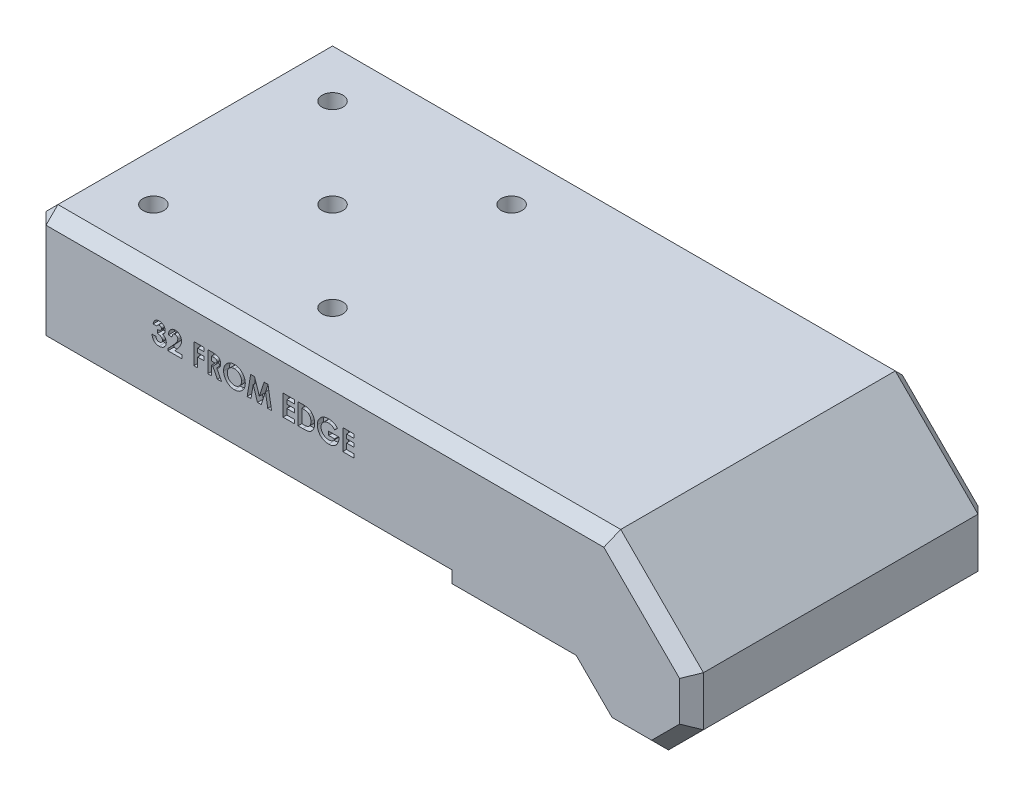
from build123d import *
from OCP.BRepFilletAPI import BRepFilletAPI_MakeChamfer

# Parameters (mm, degrees)
BOSS_EXTRUDE1_DEPTH = 50
SKETCH2_R           = 1.75
CUT_EXTRUDE1_DEPTH  = 107.695829347
CHAMFER1_SIZE       = 2
CHAMFER1_SIZE2      = 0.352653961
CUT_EXTRUDE2_DEPTH  = 1
CHAMFER2_SIZE       = 2


with BuildPart() as part:
    # Sketch1 → Boss-Extrude1 (new body)
    with BuildSketch(Plane.XY):
        Polygon((6, -6), (14.284271247, -6), (20.142135624, -0.142135624), (20.142135624, 8.142135624), (6.284271247, 22), (-90, 22), (-90, 2), (-22, 2), (-22, 0), (0, 0), align=None)
    extrude(amount=BOSS_EXTRUDE1_DEPTH)

    # Sketch2 → Cut-Extrude1 (cut, through all)
    with BuildSketch(Plane(origin=(0, 22, 0), x_dir=(1, 0, 0), z_dir=(0, 1, 0))):
        with Locations(Location((-80, -10, 0), (0, 0, 180))):
            Circle(SKETCH2_R)
        with Locations(Location((-50, -10, 0), (0, 0, 180))):
            Circle(SKETCH2_R)
        with Locations(Location((-50, -40, 0), (0, 0, 270))):
            Circle(SKETCH2_R)
        with Locations(Location((-80, -40, 0), (0, 0, 270))):
            Circle(SKETCH2_R)
        with Locations(Location((-65, -25, 0), (0, 0, 180))):
            Circle(SKETCH2_R)
    extrude(amount=-CUT_EXTRUDE1_DEPTH, mode=Mode.SUBTRACT)

    # Chamfer1: one chamfer whose edges measure the first distance from different faces: ONE call of the kernel's chamfer builder (chamfer() names one face for all edges)
    chamfer1_edges_1 = [part.edges().sort_by_distance(p)[0] for p in [
        (-80, 2, 38.25),
    ]]
    chamfer1_side_1 = [part.faces().sort_by_distance(p)[0] for p in [
        (-80, 12, 38.25),
    ]]
    chamfer1_edges_2 = [part.edges().sort_by_distance(p)[0] for p in [
        (-50, 2, 38.25),
    ]]
    chamfer1_side_2 = [part.faces().sort_by_distance(p)[0] for p in [
        (-50, 12, 38.25),
    ]]
    chamfer1_edges_3 = [part.edges().sort_by_distance(p)[0] for p in [
        (-63.25, 2, 25),
    ]]
    chamfer1_side_3 = [part.faces().sort_by_distance(p)[0] for p in [
        (-63.25, 12, 25),
    ]]
    chamfer1_edges_4 = [part.edges().sort_by_distance(p)[0] for p in [
        (-48.25, 2, 10),
    ]]
    chamfer1_side_4 = [part.faces().sort_by_distance(p)[0] for p in [
        (-48.25, 12, 10),
    ]]
    chamfer1_edges_5 = [part.edges().sort_by_distance(p)[0] for p in [
        (-78.25, 2, 10),
    ]]
    chamfer1_side_5 = [part.faces().sort_by_distance(p)[0] for p in [
        (-78.25, 12, 10),
    ]]
    chamfer1 = BRepFilletAPI_MakeChamfer(part.part.solid().wrapped)
    for e in chamfer1_edges_1:
        chamfer1.Add(CHAMFER1_SIZE, CHAMFER1_SIZE2, e.wrapped, chamfer1_side_1[0].wrapped)  # the first distance lies on this face
    for e in chamfer1_edges_2:
        chamfer1.Add(CHAMFER1_SIZE, CHAMFER1_SIZE2, e.wrapped, chamfer1_side_2[0].wrapped)  # the first distance lies on this face
    for e in chamfer1_edges_3:
        chamfer1.Add(CHAMFER1_SIZE, CHAMFER1_SIZE2, e.wrapped, chamfer1_side_3[0].wrapped)  # the first distance lies on this face
    for e in chamfer1_edges_4:
        chamfer1.Add(CHAMFER1_SIZE, CHAMFER1_SIZE2, e.wrapped, chamfer1_side_4[0].wrapped)  # the first distance lies on this face
    for e in chamfer1_edges_5:
        chamfer1.Add(CHAMFER1_SIZE, CHAMFER1_SIZE2, e.wrapped, chamfer1_side_5[0].wrapped)  # the first distance lies on this face
    add(Compound.cast(chamfer1.Shape()), mode=Mode.REPLACE)

    # Sketch5 → Cut-Extrude2 (cut)
    with BuildSketch(Plane.XY.offset(50)):
        with BuildLine():
            Line((-69.421034428, 14.652178941), (-70.049239557, 14.652178941))
            add(Edge.make_bspline(
                [(-70.049239557, 14.652178941), (-70.04480419, 14.683580675), (-70.036108946, 14.745141693), (-70.015302391, 14.834266711), (-69.990415507, 14.91880789), (-69.959345503, 14.998497506), (-69.922905443, 15.073477512), (-69.881465882, 15.144005203), (-69.834578842, 15.20977786), (-69.798639429, 15.24939957), (-69.780709909, 15.269166121)],
                knots=[0, 0, 0, 0, 1.111473889, 2.178970933, 3.205615836, 4.199322666, 5.174200091, 6.12565194, 7.064921805, 8, 8, 8, 8], degree=3))
            add(Edge.make_bspline(
                [(-69.780709909, 15.269166121), (-69.754848952, 15.295246653), (-69.703879724, 15.346648641), (-69.618704166, 15.412488909), (-69.529424451, 15.469469184), (-69.434250036, 15.514643558), (-69.334661905, 15.55120698), (-69.229868101, 15.575766713), (-69.120296847, 15.592062313), (-69.045528251, 15.593667487), (-69.007372569, 15.594486634)],
                knots=[0, 0, 0, 0, 1.01925491, 2.00884431, 2.983262333, 3.955970413, 4.92937149, 5.924503185, 6.940838805, 8, 8, 8, 8], degree=3))
            add(Edge.make_bspline(
                [(-69.007372569, 15.594486634), (-68.973450205, 15.593685793), (-68.906765673, 15.592111502), (-68.808756189, 15.579473947), (-68.715312348, 15.557309083), (-68.625446422, 15.52832902), (-68.540480045, 15.488896802), (-68.458537928, 15.443124389), (-68.381909535, 15.386982623), (-68.31041557, 15.323548077), (-68.244734728, 15.254937406), (-68.187854832, 15.181598241), (-68.138954164, 15.10548964), (-68.098666481, 15.025979285), (-68.067690728, 14.942932634), (-68.046192637, 14.856829438), (-68.032121615, 14.767859688), (-68.030719773, 14.707388148), (-68.030008787, 14.676718204)],
                knots=[0, 0, 0, 0, 1.091422571, 2.145516843, 3.172569842, 4.178562979, 5.178154469, 6.181868002, 7.194278174, 8.227918432, 9.254613415, 10.245994977, 11.209837596, 12.161663635, 13.10878368, 14.055455738, 15.013766427, 16, 16, 16, 16], degree=3))
            add(Edge.make_bspline(
                [(-68.030008787, 14.676718204), (-68.031467773, 14.638736033), (-68.034340066, 14.563960815), (-68.057909311, 14.454521727), (-68.094801589, 14.34987843), (-68.148096073, 14.251495039), (-68.214727752, 14.159639299), (-68.296482591, 14.077382223), (-68.391031999, 14.003434133), (-68.462011499, 13.96369442), (-68.498358146, 13.943344807)],
                knots=[0, 0, 0, 0, 0.992805628, 1.954529043, 2.915727527, 3.886831945, 4.871318353, 5.87440735, 6.911542536, 8, 8, 8, 8], degree=3))
            add(Edge.make_bspline(
                [(-68.498358146, 13.943344807), (-68.473410365, 13.935153925), (-68.424389094, 13.91905921), (-68.354711251, 13.88736085), (-68.288455585, 13.852719796), (-68.226762993, 13.812476024), (-68.169019869, 13.768256812), (-68.115578222, 13.71968416), (-68.06611875, 13.666863978), (-68.021448858, 13.609505774), (-67.981802584, 13.548526883), (-67.946230094, 13.48533588), (-67.916951951, 13.418974462), (-67.892149719, 13.350200521), (-67.873266712, 13.278395954), (-67.859971387, 13.203838997), (-67.852286364, 13.126699719), (-67.851114266, 13.074437905), (-67.850521608, 13.048012275)],
                knots=[0, 0, 0, 0, 1.059543567, 2.081955587, 3.086750234, 4.076226789, 5.052108497, 6.020845489, 6.989030705, 7.970690546, 8.952259656, 9.923888338, 10.895517021, 11.877585046, 12.873342345, 13.889638361, 14.932918083, 16, 16, 16, 16], degree=3))
            add(Edge.make_bspline(
                [(-67.850521608, 13.048012275), (-67.851723006, 13.009177327), (-67.854091919, 12.93260272), (-67.869152359, 12.81981616), (-67.897192184, 12.712284196), (-67.934080127, 12.60876951), (-67.98328464, 12.510608438), (-68.041190079, 12.41554832), (-68.112367499, 12.326885812), (-68.191468979, 12.242276908), (-68.279315784, 12.165354282), (-68.374556012, 12.098665826), (-68.475095412, 12.041435265), (-68.581570069, 11.994973866), (-68.693942989, 11.959193274), (-68.811963705, 11.933329413), (-68.936128107, 11.917505475), (-69.020880026, 11.915846636), (-69.064163435, 11.914999454)],
                knots=[0, 0, 0, 0, 1.005138573, 1.981928558, 2.936866704, 3.876260664, 4.820238198, 5.773547, 6.751179199, 7.756627054, 8.768222608, 9.766606018, 10.760583154, 11.757261445, 12.767156078, 13.807575856, 14.880313354, 16, 16, 16, 16], degree=3))
            add(Edge.make_bspline(
                [(-69.064163435, 11.914999454), (-69.105108842, 11.915892664), (-69.185172167, 11.917639217), (-69.302281537, 11.932756518), (-69.413582908, 11.957141952), (-69.519360323, 11.991515242), (-69.619204538, 12.036091526), (-69.714020978, 12.089171879), (-69.801917603, 12.15381785), (-69.883873753, 12.227111201), (-69.958071396, 12.309342178), (-70.024386615, 12.398605943), (-70.081357148, 12.495241928), (-70.129216634, 12.598837266), (-70.167590917, 12.709573692), (-70.197860439, 12.82722602), (-70.219004196, 12.952024104), (-70.225443572, 13.037887841), (-70.228726736, 13.081666121)],
                knots=[0, 0, 0, 0, 1.066544725, 2.085487077, 3.070979577, 4.031932826, 4.977951092, 5.916076795, 6.857635327, 7.814973522, 8.776389752, 9.738577119, 10.707772778, 11.69409279, 12.707140348, 13.757286496, 14.856535458, 16, 16, 16, 16], degree=3))
            Line((-70.228726736, 13.081666121), (-69.600521608, 13.081666121))
            add(Edge.make_bspline(
                [(-69.600521608, 13.081666121), (-69.596540738, 13.059653827), (-69.588786948, 13.016779113), (-69.573663658, 12.954706057), (-69.553955902, 12.897408793), (-69.531168832, 12.844378064), (-69.506555365, 12.794917595), (-69.476816412, 12.750854082), (-69.444131086, 12.710991023), (-69.396965922, 12.663601378), (-69.329540072, 12.614910496), (-69.238492837, 12.572595803), (-69.13721141, 12.547794195), (-69.066405591, 12.544768474), (-69.029808467, 12.543204582)],
                knots=[0, 0, 0, 0, 0.928156231, 1.807827665, 2.648129825, 3.438902246, 4.202261636, 4.936546065, 5.639352463, 6.338805438, 7.70633318, 9.064371875, 10.482673459, 12, 12, 12, 12], degree=3))
            add(Edge.make_bspline(
                [(-69.029808467, 12.543204582), (-69.010388739, 12.543537599), (-68.972349837, 12.544189903), (-68.916476354, 12.551419819), (-68.863248994, 12.563327496), (-68.812568618, 12.579509589), (-68.764112594, 12.599794854), (-68.71880672, 12.625951489), (-68.67572755, 12.656362311), (-68.635343395, 12.690552148), (-68.598027603, 12.727806831), (-68.566978669, 12.769060064), (-68.538602191, 12.810980722), (-68.517614743, 12.856311402), (-68.499225217, 12.902612829), (-68.487969888, 12.9515656), (-68.479471306, 13.002142818), (-68.478977402, 13.036755646), (-68.478726736, 13.054322371)],
                knots=[0, 0, 0, 0, 1.110435564, 2.175094844, 3.216326037, 4.226890168, 5.215276772, 6.21526065, 7.213097102, 8.228249917, 9.239874822, 10.221364777, 11.178138315, 12.128914389, 13.072518965, 14.022636769, 14.996447288, 16, 16, 16, 16], degree=3))
            add(Edge.make_bspline(
                [(-68.478726736, 13.054322371), (-68.479392208, 13.073534578), (-68.48071701, 13.11178168), (-68.491540782, 13.167595284), (-68.508633805, 13.221283472), (-68.532378101, 13.272608488), (-68.564085963, 13.321381159), (-68.601500887, 13.368580012), (-68.647570549, 13.41174843), (-68.698115138, 13.454419103), (-68.756727005, 13.491615061), (-68.82055167, 13.525941465), (-68.891266544, 13.553254685), (-68.967145413, 13.577650449), (-69.049623598, 13.595468736), (-69.138188939, 13.60840655), (-69.232698568, 13.618036747), (-69.297845283, 13.619418357), (-69.331290839, 13.620127659)],
                knots=[0, 0, 0, 0, 0.809814727, 1.612155564, 2.388397, 3.182215007, 3.988903953, 4.837162975, 5.715530372, 6.646997145, 7.623086902, 8.637258368, 9.698941581, 10.815059213, 11.996518529, 13.252603015, 14.589518788, 16, 16, 16, 16], degree=3))
            Line((-69.331290839, 13.620127659), (-69.331290839, 14.203460993))
            add(Edge.make_bspline(
                [(-69.331290839, 14.203460993), (-69.289649133, 14.207007334), (-69.211745749, 14.213641835), (-69.103611674, 14.229156847), (-69.012576722, 14.249895216), (-68.936452866, 14.274914935), (-68.873244494, 14.307046773), (-68.818026009, 14.342518902), (-68.770469238, 14.383714597), (-68.730277387, 14.429405407), (-68.698125156, 14.478473052), (-68.675369681, 14.530154876), (-68.660343154, 14.582851779), (-68.658919391, 14.618894872), (-68.658213916, 14.636754262)],
                knots=[0, 0, 0, 0, 1.70044513, 3.18119609, 4.440695891, 5.496282586, 6.431922213, 7.318171381, 8.16090191, 8.983045123, 9.787564368, 10.536848927, 11.275007137, 12, 12, 12, 12], degree=3))
            add(Edge.make_bspline(
                [(-68.658213916, 14.636754262), (-68.659431063, 14.659540904), (-68.661806677, 14.704015606), (-68.680256985, 14.767668273), (-68.712284627, 14.82440935), (-68.755228073, 14.874119438), (-68.807556154, 14.915641029), (-68.868893838, 14.945784996), (-68.937910094, 14.963495922), (-68.986466749, 14.965331949), (-69.0115793, 14.966281506)],
                knots=[0, 0, 0, 0, 1.009664648, 1.970651636, 2.907870547, 3.878035693, 4.867062054, 5.849714035, 6.887914197, 8, 8, 8, 8], degree=3))
            add(Edge.make_bspline(
                [(-69.0115793, 14.966281506), (-69.034341004, 14.965161128), (-69.079507197, 14.962937957), (-69.14555369, 14.946344793), (-69.208275853, 14.918412266), (-69.266374889, 14.879894958), (-69.319012125, 14.833637304), (-69.36221211, 14.778854714), (-69.398143808, 14.718829309), (-69.413374309, 14.674482826), (-69.421034428, 14.652178941)],
                knots=[0, 0, 0, 0, 0.98818071, 1.960853194, 2.938124878, 3.957524365, 4.978590984, 5.968022688, 6.978025184, 8, 8, 8, 8], degree=3))
        make_face()
        with BuildLine():
            Line((-66.863342121, 14.338076377), (-67.491547249, 14.338076377))
            add(Edge.make_bspline(
                [(-67.491547249, 14.338076377), (-67.488834127, 14.385596772), (-67.483532851, 14.47844877), (-67.462445712, 14.613319269), (-67.434189669, 14.740757061), (-67.39647823, 14.860316352), (-67.349091338, 14.9719537), (-67.293248382, 15.076049682), (-67.2275227, 15.17205623), (-67.153313151, 15.259510348), (-67.071879609, 15.337966243), (-66.984912714, 15.407530169), (-66.891082191, 15.464932569), (-66.792102399, 15.512169431), (-66.687990194, 15.549909488), (-66.57776051, 15.575141771), (-66.462367775, 15.592229319), (-66.383372104, 15.593724548), (-66.343109749, 15.594486634)],
                knots=[0, 0, 0, 0, 1.199038563, 2.342849363, 3.436047546, 4.486744587, 5.497670872, 6.488682221, 7.459191391, 8.424610317, 9.374430501, 10.305433194, 11.225809216, 12.140057399, 13.06607119, 14.010487599, 14.985989317, 16, 16, 16, 16], degree=3))
            add(Edge.make_bspline(
                [(-66.343109749, 15.594486634), (-66.293688279, 15.592944554), (-66.197205989, 15.589934052), (-66.057009568, 15.564253472), (-65.92608144, 15.521298735), (-65.804516776, 15.461279638), (-65.693350479, 15.385031667), (-65.592600982, 15.29411844), (-65.505315112, 15.186632551), (-65.430939449, 15.067046311), (-65.369142162, 14.940421314), (-65.325837197, 14.809485816), (-65.29737331, 14.677714314), (-65.294337461, 14.588986055), (-65.2928293, 14.544907307)],
                knots=[0, 0, 0, 0, 1.075374347, 2.099382735, 3.09057751, 4.06680945, 5.040638231, 6.016817125, 7.011024321, 8.044445721, 9.0776792, 10.070479129, 11.0414456, 12, 12, 12, 12], degree=3))
            add(Edge.make_bspline(
                [(-65.2928293, 14.544907307), (-65.293416498, 14.518245365), (-65.294598383, 14.464581462), (-65.302816184, 14.383374805), (-65.315144509, 14.300656331), (-65.333732618, 14.216496963), (-65.356913515, 14.130873109), (-65.385035293, 14.043528528), (-65.418750265, 13.95495843), (-65.457495796, 13.864165975), (-65.503719314, 13.770856395), (-65.557540174, 13.673630943), (-65.620386906, 13.572575865), (-65.691500399, 13.467120573), (-65.771226036, 13.357431384), (-65.85995301, 13.243838717), (-65.956659395, 13.125942309), (-66.025294636, 13.047135176), (-66.060557666, 13.006646089)],
                knots=[0, 0, 0, 0, 0.728284026, 1.46585585, 2.227944881, 3.01186502, 3.81876927, 4.650621989, 5.517437689, 6.406905708, 7.346299482, 8.360816762, 9.441613733, 10.596154504, 11.834900912, 13.145207542, 14.533280747, 16, 16, 16, 16], degree=3))
            Line((-66.060557666, 13.006646089), (-66.425842121, 12.588076377))
            Line((-66.425842121, 12.588076377), (-65.247957505, 12.588076377))
            Line((-65.247957505, 12.588076377), (-65.247957505, 12.004743044))
            Line((-65.247957505, 12.004743044), (-67.581290839, 12.004743044))
            Line((-67.581290839, 12.004743044), (-67.581290839, 12.323052339))
            Line((-67.581290839, 12.323052339), (-66.545032826, 13.425916922))
            add(Edge.make_bspline(
                [(-66.545032826, 13.425916922), (-66.515030493, 13.458087825), (-66.456924873, 13.520393322), (-66.374246563, 13.611895574), (-66.299429996, 13.698729026), (-66.234026554, 13.781818281), (-66.174603949, 13.85846826), (-66.12381183, 13.930989291), (-66.081185488, 13.998725756), (-66.034908549, 14.080404103), (-65.990960669, 14.177820066), (-65.95063583, 14.29004725), (-65.92605505, 14.397310591), (-65.922662125, 14.46720569), (-65.921034428, 14.500736634)],
                knots=[0, 0, 0, 0, 1.246127091, 2.413378631, 3.493388633, 4.492180848, 5.408488754, 6.240484944, 6.999099869, 7.674939598, 8.898438119, 10.020720584, 11.050475521, 12, 12, 12, 12], degree=3))
            add(Edge.make_bspline(
                [(-65.921034428, 14.500736634), (-65.922251417, 14.533175235), (-65.924609529, 14.596030226), (-65.950523262, 14.685441117), (-65.990669717, 14.76639355), (-66.047241741, 14.836468578), (-66.11576818, 14.894053875), (-66.194956918, 14.9368842), (-66.284162332, 14.961597102), (-66.346697028, 14.964690275), (-66.37886696, 14.966281506)],
                knots=[0, 0, 0, 0, 1.062038974, 2.057870785, 3.028805853, 4.01125022, 4.991535629, 5.949134679, 6.94496649, 8, 8, 8, 8], degree=3))
            add(Edge.make_bspline(
                [(-66.37886696, 14.966281506), (-66.395486357, 14.965693686), (-66.428204309, 14.964536468), (-66.476297141, 14.956833183), (-66.522060926, 14.943256947), (-66.56600504, 14.925066702), (-66.6076605, 14.900955402), (-66.646922238, 14.871234382), (-66.684203926, 14.836658923), (-66.719334575, 14.797337136), (-66.751308052, 14.753454011), (-66.779706777, 14.705410329), (-66.803187795, 14.653235914), (-66.823861336, 14.597619546), (-66.839805761, 14.537963861), (-66.85141528, 14.474625892), (-66.860241222, 14.40770868), (-66.862289684, 14.36170939), (-66.863342121, 14.338076377)],
                knots=[0, 0, 0, 0, 0.903469896, 1.778625579, 2.63899355, 3.493148037, 4.358286772, 5.247621495, 6.164656832, 7.118446693, 8.109501108, 9.111810964, 10.146451449, 11.215617525, 12.33435995, 13.498009769, 14.714554818, 16, 16, 16, 16], degree=3))
        make_face()
        Polygon((-63.228726736, 15.504743044), (-61.523598531, 15.504743044), (-61.523598531, 14.876537916), (-62.600521608, 14.876537916), (-62.600521608, 14.203460993), (-61.523598531, 14.203460993), (-61.523598531, 13.575255865), (-62.600521608, 13.575255865), (-62.600521608, 12.004743044), (-63.228726736, 12.004743044), align=None)
        with BuildLine():
            Line((-60.895393403, 15.504743044), (-60.163422249, 15.504743044))
            add(Edge.make_bspline(
                [(-60.163422249, 15.504743044), (-60.115039178, 15.504571312), (-60.021984905, 15.504241023), (-59.887805726, 15.499029933), (-59.764543697, 15.491778274), (-59.652016317, 15.48071205), (-59.550271729, 15.466039574), (-59.45920796, 15.448743153), (-59.378827672, 15.429030174), (-59.308452968, 15.404466246), (-59.244943277, 15.376758507), (-59.185743416, 15.344921808), (-59.129547347, 15.309310659), (-59.076730681, 15.268988035), (-59.026834428, 15.22467933), (-58.979764456, 15.176339943), (-58.936185907, 15.123559976), (-58.896368622, 15.066672931), (-58.860078372, 15.006829064), (-58.828005402, 14.94394621), (-58.801923609, 14.877980636), (-58.778877549, 14.809885689), (-58.762278219, 14.738687938), (-58.750733628, 14.665080505), (-58.74228113, 14.588804284), (-58.741795152, 14.536985606), (-58.741547249, 14.510552339)],
                knots=[0, 0, 0, 0, 1.749336639, 3.364467119, 4.854658419, 6.213483162, 7.451590619, 8.570285859, 9.5643256, 10.440900261, 11.26203566, 12.067320669, 12.869050712, 13.665104639, 14.467235401, 15.27997916, 16.102287765, 16.939272006, 17.78853747, 18.631303466, 19.488103222, 20.351255419, 21.228522269, 22.127379805, 23.044756219, 24, 24, 24, 24], degree=3))
            add(Edge.make_bspline(
                [(-58.741547249, 14.510552339), (-58.742191211, 14.48296208), (-58.743453904, 14.428862612), (-58.750255452, 14.349394905), (-58.762686546, 14.273365761), (-58.781515247, 14.200997785), (-58.803156393, 14.131390273), (-58.831933565, 14.065827526), (-58.864411448, 14.00335603), (-58.902984482, 13.944859468), (-58.945316501, 13.889038513), (-58.994547749, 13.838031875), (-59.047488798, 13.789098138), (-59.107115655, 13.745302347), (-59.170799914, 13.703683189), (-59.239806915, 13.665965147), (-59.313686293, 13.631200079), (-59.365627154, 13.611812675), (-59.392188275, 13.601898493)],
                knots=[0, 0, 0, 0, 1.099860209, 2.156625411, 3.176576793, 4.16617041, 5.135385252, 6.078461593, 7.016046972, 7.938469504, 8.868247731, 9.803980173, 10.76021508, 11.73834243, 12.748633912, 13.790971185, 14.870363756, 16, 16, 16, 16], degree=3))
            Line((-59.392188275, 13.601898493), (-58.584495967, 12.004743044))
            Line((-58.584495967, 12.004743044), (-59.282813275, 12.004743044))
            Line((-59.282813275, 12.004743044), (-60.054047249, 13.53038407))
            Line((-60.054047249, 13.53038407), (-60.267188275, 13.53038407))
            Line((-60.267188275, 13.53038407), (-60.267188275, 12.004743044))
            Line((-60.267188275, 12.004743044), (-60.895393403, 12.004743044))
            Line((-60.895393403, 12.004743044), (-60.895393403, 15.504743044))
        make_face()
        with BuildLine():
            Line((-60.267188275, 14.158589198), (-60.022496768, 14.158589198))
            add(Edge.make_bspline(
                [(-60.022496768, 14.158589198), (-59.992581198, 14.158926127), (-59.935299308, 14.159571274), (-59.852920427, 14.162563734), (-59.778100757, 14.169774084), (-59.710518996, 14.178884091), (-59.64983508, 14.18940291), (-59.596590288, 14.204477016), (-59.549964199, 14.220629302), (-59.510509333, 14.240702405), (-59.476800002, 14.263529875), (-59.447694152, 14.289462449), (-59.423619441, 14.319476102), (-59.403804726, 14.352755191), (-59.388391032, 14.389594063), (-59.377140216, 14.429588309), (-59.370852674, 14.473193516), (-59.370129271, 14.503287046), (-59.369752377, 14.5189658)],
                knots=[0, 0, 0, 0, 1.688639943, 3.233382647, 4.650958383, 5.928841754, 7.082724185, 8.122798841, 9.049171256, 9.863274652, 10.613301712, 11.341792392, 12.054588806, 12.776240173, 13.521029143, 14.301969904, 15.115324896, 16, 16, 16, 16], degree=3))
            add(Edge.make_bspline(
                [(-59.369752377, 14.5189658), (-59.370464929, 14.537514912), (-59.371864605, 14.573951203), (-59.385753743, 14.626406687), (-59.40786225, 14.674957826), (-59.438166957, 14.719385254), (-59.476331796, 14.758333405), (-59.52012896, 14.792666509), (-59.570503697, 14.81981456), (-59.617146913, 14.837721125), (-59.659581337, 14.848434807), (-59.697877065, 14.856418549), (-59.74222375, 14.862076856), (-59.79265487, 14.868078497), (-59.849041874, 14.871970258), (-59.911692105, 14.874810467), (-59.980425633, 14.875972537), (-60.02833943, 14.87634403), (-60.053346127, 14.876537916)],
                knots=[0, 0, 0, 0, 1.020303359, 2.004196876, 2.966617323, 3.9489082, 4.950758222, 5.960522915, 7.003732012, 8.091992268, 8.70421221, 9.413913587, 10.24622431, 11.166358409, 12.212345909, 13.359657661, 14.621978493, 16, 16, 16, 16], degree=3))
            Line((-60.053346127, 14.876537916), (-60.267188275, 14.876537916))
            Line((-60.267188275, 14.876537916), (-60.267188275, 14.158589198))
        make_face(mode=Mode.SUBTRACT)
        with BuildLine():
            add(Edge.make_bspline(
                [(-56.423638595, 15.594486634), (-56.362786806, 15.592911072), (-56.242651591, 15.589800556), (-56.065976041, 15.563871979), (-55.895716483, 15.521625079), (-55.731949905, 15.462898833), (-55.575086362, 15.386102636), (-55.424572542, 15.293413709), (-55.280947579, 15.183082605), (-55.145683227, 15.057683167), (-55.02067457, 14.921316754), (-54.912354495, 14.774494065), (-54.81998311, 14.621019426), (-54.743425458, 14.460481595), (-54.685112557, 14.291768773), (-54.644191982, 14.11574117), (-54.61790254, 13.932448866), (-54.61487885, 13.80765179), (-54.613342121, 13.744226217)],
                knots=[0, 0, 0, 0, 1.014329547, 2.002516266, 2.970391464, 3.935626869, 4.897733899, 5.877609409, 6.878433252, 7.912639331, 8.949961323, 9.958554974, 10.949718813, 11.932905612, 12.9188844, 13.919928257, 14.942845884, 16, 16, 16, 16], degree=3))
            add(Edge.make_bspline(
                [(-54.613342121, 13.744226217), (-54.614978671, 13.681515304), (-54.618203545, 13.557941437), (-54.643118732, 13.376338243), (-54.684728414, 13.202196263), (-54.742052283, 13.035121322), (-54.817221468, 12.875922673), (-54.907791511, 12.723583856), (-55.016152383, 12.57951861), (-55.138351738, 12.443804248), (-55.272882622, 12.320614342), (-55.415372185, 12.212053451), (-55.565162498, 12.120063048), (-55.722034316, 12.044685271), (-55.886324043, 11.986187354), (-56.057625862, 11.944912822), (-56.235929175, 11.919829456), (-56.357184074, 11.916625647), (-56.418730743, 11.914999454)],
                knots=[0, 0, 0, 0, 1.051557043, 2.072126891, 3.067553643, 4.050577992, 5.02905126, 6.015227836, 7.017913613, 8.04756643, 9.074058332, 10.072836633, 11.047628519, 12.017157415, 12.98668631, 13.966869689, 14.968021931, 16, 16, 16, 16], degree=3))
            add(Edge.make_bspline(
                [(-56.418730743, 11.914999454), (-56.483101178, 11.916458229), (-56.609580284, 11.919324522), (-56.794683023, 11.946581662), (-56.972027441, 11.987640435), (-57.140123743, 12.048918452), (-57.300683846, 12.125521125), (-57.452528068, 12.219861911), (-57.595605379, 12.331784902), (-57.729095065, 12.45842371), (-57.850037043, 12.596994342), (-57.956792062, 12.743381926), (-58.046842289, 12.896468191), (-58.120191018, 13.056324783), (-58.178016209, 13.221958233), (-58.218805312, 13.394377296), (-58.242900408, 13.573168449), (-58.246256715, 13.694606975), (-58.247957505, 13.756145288)],
                knots=[0, 0, 0, 0, 1.067978421, 2.098431617, 3.099715153, 4.085208694, 5.062210972, 6.048429807, 7.046490867, 8.072918869, 9.098532598, 10.095778865, 11.076610158, 12.041847152, 13.011192615, 13.984257998, 14.978533688, 16, 16, 16, 16], degree=3))
            add(Edge.make_bspline(
                [(-58.247957505, 13.756145288), (-58.247423699, 13.797545043), (-58.246362847, 13.879820338), (-58.233583758, 14.001748126), (-58.215185543, 14.121296047), (-58.187975458, 14.237987462), (-58.154922158, 14.352645574), (-58.112096939, 14.464203119), (-58.063350251, 14.573851836), (-58.006394335, 14.680296637), (-57.943064864, 14.782558141), (-57.873966772, 14.880153964), (-57.798926314, 14.971904027), (-57.71818522, 15.058411276), (-57.631465245, 15.139107092), (-57.5399071, 15.215133837), (-57.441735091, 15.284471969), (-57.339097895, 15.348814864), (-57.232574157, 15.406999029), (-57.122597525, 15.456523649), (-57.011433735, 15.499772657), (-56.897597789, 15.533906686), (-56.782309641, 15.561708496), (-56.664337672, 15.580094309), (-56.54474769, 15.592873045), (-56.464104099, 15.593947494), (-56.423638595, 15.594486634)],
                knots=[0, 0, 0, 0, 1.034744296, 2.056386356, 3.06226378, 4.057406941, 5.050368692, 6.043467995, 7.042652155, 8.049140477, 9.059438543, 10.048523776, 11.036952808, 12.020949711, 13.004946614, 13.997082645, 14.994316842, 16.007702937, 17.024872941, 18.026463647, 19.021641123, 20.005082605, 20.995858141, 21.984425357, 22.988620895, 24, 24, 24, 24], degree=3))
        make_face()
        with BuildLine():
            add(Edge.make_bspline(
                [(-56.4334543, 14.966281506), (-56.474407546, 14.965182638), (-56.555232867, 14.963013913), (-56.673788892, 14.946491163), (-56.787606862, 14.920102454), (-56.896055841, 14.881878731), (-56.999605855, 14.833229632), (-57.098440466, 14.774325144), (-57.191191019, 14.703140491), (-57.279094253, 14.623497259), (-57.358500361, 14.534756396), (-57.428658162, 14.439655469), (-57.487368941, 14.338353295), (-57.536539586, 14.231790948), (-57.573554184, 14.118770162), (-57.599918573, 14.000176241), (-57.616579882, 13.875804842), (-57.618680061, 13.791021022), (-57.619752377, 13.747731826)],
                knots=[0, 0, 0, 0, 1.033739768, 2.040188636, 3.016340934, 3.979330865, 4.937572243, 5.900995986, 6.878200029, 7.884839167, 8.891893314, 9.879764717, 10.863503415, 11.843163062, 12.837761627, 13.859916423, 14.907309254, 16, 16, 16, 16], degree=3))
            add(Edge.make_bspline(
                [(-57.619752377, 13.747731826), (-57.61833065, 13.69975766), (-57.6155443, 13.605736243), (-57.595939203, 13.468580332), (-57.562396832, 13.339050188), (-57.513962302, 13.217779322), (-57.453890778, 13.103421112), (-57.379291479, 12.99737718), (-57.29137256, 12.899012586), (-57.223640537, 12.841583239), (-57.189263595, 12.812435352)],
                knots=[0, 0, 0, 0, 1.078454662, 2.113592447, 3.107694534, 4.079536787, 5.043276885, 6.005368276, 6.987637804, 8, 8, 8, 8], degree=3))
            add(Edge.make_bspline(
                [(-57.189263595, 12.812435352), (-57.161102317, 12.790902012), (-57.105414238, 12.748320483), (-57.01652394, 12.693743518), (-56.924984437, 12.646965615), (-56.830104947, 12.609169622), (-56.732085853, 12.57943993), (-56.630940594, 12.558620715), (-56.526812486, 12.545554858), (-56.456396179, 12.54399324), (-56.420834108, 12.543204582)],
                knots=[0, 0, 0, 0, 1.023928204, 2.024787132, 3.009472467, 3.9914905, 4.972207045, 5.96565515, 6.972602802, 8, 8, 8, 8], degree=3))
            add(Edge.make_bspline(
                [(-56.420834108, 12.543204582), (-56.380585054, 12.544312767), (-56.301393774, 12.546493156), (-56.185044733, 12.562812501), (-56.073578818, 12.590430726), (-55.96630404, 12.628319137), (-55.86352973, 12.677579067), (-55.765758174, 12.738310588), (-55.672817954, 12.809767993), (-55.585026707, 12.890457115), (-55.504781357, 12.979547556), (-55.434769961, 13.075155742), (-55.374192473, 13.175175137), (-55.326044332, 13.281021366), (-55.28756737, 13.391695289), (-55.261520291, 13.507687056), (-55.244718231, 13.628518507), (-55.242617461, 13.710748579), (-55.241547249, 13.752639679)],
                knots=[0, 0, 0, 0, 1.026359118, 2.019393844, 2.989460624, 3.950973911, 4.916101784, 5.890408035, 6.881132271, 7.902007068, 8.92769091, 9.933912415, 10.920395702, 11.90457117, 12.894218921, 13.903490204, 14.931958862, 16, 16, 16, 16], degree=3))
            add(Edge.make_bspline(
                [(-55.241547249, 13.752639679), (-55.24265449, 13.794289893), (-55.244833925, 13.876271987), (-55.261181994, 13.99679278), (-55.288625072, 14.112272479), (-55.326627258, 14.222899671), (-55.375154037, 14.328782815), (-55.435162323, 14.429549561), (-55.506441553, 14.525102493), (-55.58735124, 14.614790454), (-55.675416463, 14.697207945), (-55.769963278, 14.768731346), (-55.868346161, 14.830882907), (-55.972822494, 14.87956993), (-56.081254779, 14.918358778), (-56.194304677, 14.946923443), (-56.312400369, 14.96289784), (-56.39274331, 14.965143563), (-56.4334543, 14.966281506)],
                knots=[0, 0, 0, 0, 1.055025985, 2.07665775, 3.074803781, 4.057872707, 5.035505728, 6.020516407, 7.023567878, 8.050795229, 9.077271434, 10.074415901, 11.050397877, 12.019801805, 12.988065821, 13.964604439, 14.968634123, 16, 16, 16, 16], degree=3))
        make_face(mode=Mode.SUBTRACT)
        Polygon((-53.708193884, 15.504743044), (-53.057552858, 15.504743044), (-52.25757289, 13.063436954), (-51.453386191, 15.504743044), (-50.807653018, 15.504743044), (-50.215906223, 12.004743044), (-50.851823691, 12.004743044), (-51.225521608, 14.215380063), (-51.953286031, 12.004743044), (-52.565365358, 12.004743044), (-53.289624172, 14.215380063), (-53.662620967, 12.004743044), (-54.299239557, 12.004743044), align=None)
        Polygon((-48.286419044, 15.504743044), (-46.401803659, 15.504743044), (-46.401803659, 14.876537916), (-47.658213916, 14.876537916), (-47.658213916, 14.203460993), (-46.401803659, 14.203460993), (-46.401803659, 13.575255865), (-47.658213916, 13.575255865), (-47.658213916, 12.632948172), (-46.401803659, 12.632948172), (-46.401803659, 12.004743044), (-48.286419044, 12.004743044), align=None)
        with BuildLine():
            Line((-45.773598531, 15.504743044), (-44.982032025, 15.504743044))
            add(Edge.make_bspline(
                [(-44.982032025, 15.504743044), (-44.920320311, 15.504311658), (-44.80103087, 15.503477784), (-44.62820407, 15.494082029), (-44.467497139, 15.479632025), (-44.318806482, 15.459753426), (-44.182436938, 15.433448596), (-44.058564353, 15.400454342), (-43.946772982, 15.362367966), (-43.845837055, 15.317551615), (-43.753692262, 15.2653002), (-43.66619784, 15.207096319), (-43.583525582, 15.140807794), (-43.504515315, 15.067713462), (-43.430186682, 14.986476085), (-43.359301846, 14.898441248), (-43.293596388, 14.802332324), (-43.231084175, 14.700453703), (-43.174550196, 14.592373633), (-43.125239148, 14.479012068), (-43.083930984, 14.361098533), (-43.050365961, 14.238507362), (-43.023610764, 14.111645521), (-43.004890692, 13.980257014), (-42.993317757, 13.844463486), (-42.99214378, 13.752429544), (-42.991547249, 13.705664518)],
                knots=[0, 0, 0, 0, 1.44355588, 2.790409838, 4.047694926, 5.217575253, 6.298404546, 7.294384826, 8.214239204, 9.058592145, 9.873746385, 10.689560431, 11.514393297, 12.350027578, 13.205127629, 14.088021785, 14.991911688, 15.926770944, 16.882954281, 17.842803888, 18.816321264, 19.80318086, 20.814351908, 21.847355356, 22.906180909, 24, 24, 24, 24], degree=3))
            add(Edge.make_bspline(
                [(-42.991547249, 13.705664518), (-42.993109289, 13.639676023), (-42.996184256, 13.509773807), (-43.022086059, 13.319143801), (-43.063978046, 13.136405928), (-43.122881984, 12.962989633), (-43.195907099, 12.800439215), (-43.283143777, 12.651621181), (-43.383312923, 12.517334312), (-43.495247563, 12.398247245), (-43.616445515, 12.295890298), (-43.742394628, 12.208229063), (-43.874321875, 12.139100865), (-43.990568216, 12.095263249), (-44.091368297, 12.068000045), (-44.179869677, 12.051887229), (-44.280398215, 12.037110805), (-44.393891252, 12.025691902), (-44.519850919, 12.015509047), (-44.658779292, 12.00997608), (-44.81022656, 12.005379006), (-44.915421008, 12.004960586), (-44.970112954, 12.004743044)],
                knots=[0, 0, 0, 0, 1.315458931, 2.589557908, 3.828601765, 5.048913369, 6.235739168, 7.376350998, 8.481830359, 9.569842114, 10.627874879, 11.640079404, 12.624025415, 13.590060155, 14.111227486, 14.704434459, 15.382649715, 16.137166398, 16.978595427, 17.902333227, 18.909396075, 20, 20, 20, 20], degree=3))
            Line((-44.970112954, 12.004743044), (-45.773598531, 12.004743044))
            Line((-45.773598531, 12.004743044), (-45.773598531, 15.504743044))
        make_face()
        with BuildLine():
            Line((-45.145393403, 14.876537916), (-45.145393403, 12.632948172))
            Line((-45.145393403, 12.632948172), (-44.817268403, 12.632948172))
            add(Edge.make_bspline(
                [(-44.817268403, 12.632948172), (-44.778226567, 12.633019713), (-44.70313612, 12.63315731), (-44.594722511, 12.639711164), (-44.494467413, 12.646289425), (-44.402646803, 12.658775187), (-44.318592439, 12.672683446), (-44.243459009, 12.692038693), (-44.175697687, 12.71236974), (-44.116136162, 12.738253683), (-44.061582659, 12.767387784), (-44.011072347, 12.801521761), (-43.962315753, 12.839426254), (-43.916224423, 12.88221609), (-43.872623911, 12.929324651), (-43.831772185, 12.980994665), (-43.793123984, 13.037068486), (-43.757671333, 13.09784259), (-43.725274511, 13.16267519), (-43.696534899, 13.230938286), (-43.67270552, 13.303200364), (-43.6529, 13.378784963), (-43.638746709, 13.458350134), (-43.627037561, 13.541306547), (-43.621001154, 13.62798287), (-43.620172695, 13.686960336), (-43.619752377, 13.716882467)],
                knots=[0, 0, 0, 0, 1.50275155, 2.890291501, 4.180787663, 5.369391935, 6.45668281, 7.458360028, 8.354766181, 9.177074746, 9.954075863, 10.732690366, 11.5210699, 12.329727389, 13.151100085, 13.990027547, 14.863562427, 15.770965086, 16.696477834, 17.652329173, 18.619756807, 19.62365428, 20.657822005, 21.729286259, 22.847956731, 24, 24, 24, 24], degree=3))
            add(Edge.make_bspline(
                [(-43.619752377, 13.716882467), (-43.620589507, 13.762735304), (-43.622221846, 13.852144783), (-43.637963765, 13.98237164), (-43.663588606, 14.104999736), (-43.700152786, 14.219573963), (-43.746243067, 14.326416336), (-43.803935799, 14.424621673), (-43.870748107, 14.515839689), (-43.923581458, 14.569351104), (-43.949980743, 14.596089198)],
                knots=[0, 0, 0, 0, 1.13821349, 2.219428113, 3.251817212, 4.244760574, 5.201143372, 6.134805572, 7.068016741, 8, 8, 8, 8], degree=3))
            add(Edge.make_bspline(
                [(-43.949980743, 14.596089198), (-43.976012937, 14.618873668), (-44.029180746, 14.665408369), (-44.122525946, 14.721168841), (-44.225387523, 14.770159881), (-44.34011864, 14.809004312), (-44.465610472, 14.839724145), (-44.602610452, 14.860910862), (-44.750384913, 14.874525222), (-44.852759617, 14.875852644), (-44.905609749, 14.876537916)],
                knots=[0, 0, 0, 0, 0.813307809, 1.661089106, 2.549956539, 3.493439533, 4.508053171, 5.589449661, 6.755572447, 8, 8, 8, 8], degree=3))
            Line((-44.905609749, 14.876537916), (-45.145393403, 14.876537916))
        make_face(mode=Mode.SUBTRACT)
        with BuildLine():
            Line((-39.155709909, 14.948052339), (-39.631070486, 14.493024294))
            add(Edge.make_bspline(
                [(-39.631070486, 14.493024294), (-39.668705612, 14.530704514), (-39.742551944, 14.604639326), (-39.863318381, 14.700870565), (-39.988395758, 14.782686142), (-40.118195755, 14.849960633), (-40.252899184, 14.902144577), (-40.392240218, 14.939473422), (-40.536445546, 14.961613792), (-40.634066117, 14.964713368), (-40.6834543, 14.966281506)],
                knots=[0, 0, 0, 0, 1.075575784, 2.110457258, 3.113929901, 4.09197124, 5.059417775, 6.02750972, 7.002078037, 8, 8, 8, 8], degree=3))
            add(Edge.make_bspline(
                [(-40.6834543, 14.966281506), (-40.726272345, 14.965182719), (-40.81034933, 14.963025155), (-40.933892361, 14.946640762), (-41.051945295, 14.919271371), (-41.165065862, 14.88135565), (-41.272563424, 14.832015313), (-41.375060839, 14.77201187), (-41.471927339, 14.700886291), (-41.562400169, 14.619986869), (-41.644775971, 14.531661033), (-41.716694397, 14.437121156), (-41.777953445, 14.338129382), (-41.828382135, 14.234179253), (-41.866752885, 14.125430312), (-41.894144579, 14.011961506), (-41.911531493, 13.89410259), (-41.913584368, 13.813698018), (-41.914624172, 13.772972211)],
                knots=[0, 0, 0, 0, 1.075001177, 2.110859044, 3.123021556, 4.114053297, 5.101481495, 6.087880186, 7.091499647, 8.114004866, 9.131394192, 10.11971144, 11.092043119, 12.050101265, 13.015322563, 13.981809771, 14.977764287, 16, 16, 16, 16], degree=3))
            add(Edge.make_bspline(
                [(-41.914624172, 13.772972211), (-41.913654293, 13.730836829), (-41.911743497, 13.647824358), (-41.893388148, 13.525999989), (-41.865108573, 13.408796168), (-41.823714815, 13.297082519), (-41.772771635, 13.189328721), (-41.708167289, 13.087622069), (-41.632832157, 12.990409389), (-41.546900852, 12.899383211), (-41.453429783, 12.815478982), (-41.352197574, 12.743101034), (-41.24628433, 12.680654488), (-41.133980606, 12.631198842), (-41.017235662, 12.591491377), (-40.894865369, 12.563494206), (-40.767145276, 12.546318039), (-40.680003008, 12.544252732), (-40.635778018, 12.543204582)],
                knots=[0, 0, 0, 0, 1.022067601, 2.013613092, 2.983553406, 3.943623673, 4.90013463, 5.87121881, 6.861774014, 7.881098904, 8.905697761, 9.905387765, 10.89678721, 11.884561068, 12.87834324, 13.885584958, 14.926927371, 16, 16, 16, 16], degree=3))
            add(Edge.make_bspline(
                [(-40.635778018, 12.543204582), (-40.6070113, 12.54346414), (-40.550535832, 12.543973708), (-40.467695945, 12.552245436), (-40.38835523, 12.564070832), (-40.312206423, 12.579726253), (-40.240018423, 12.601881483), (-40.170791737, 12.627789295), (-40.104931972, 12.65836568), (-40.042796214, 12.69466558), (-39.983459702, 12.735353329), (-39.927477837, 12.781908768), (-39.873868632, 12.83328224), (-39.823258503, 12.890101347), (-39.776504042, 12.952874118), (-39.732107354, 13.02044702), (-39.690576773, 13.093490672), (-39.666037448, 13.1450704), (-39.653506384, 13.171409711)],
                knots=[0, 0, 0, 0, 1.109579412, 2.178351274, 3.208885622, 4.204702371, 5.174744997, 6.119429583, 7.05542196, 7.97267548, 8.893247984, 9.828544973, 10.778894627, 11.756245826, 12.760884819, 13.796418446, 14.874735809, 16, 16, 16, 16], degree=3))
            Line((-39.653506384, 13.171409711), (-40.658213916, 13.171409711))
            Line((-40.658213916, 13.171409711), (-40.658213916, 13.799614839))
            Line((-40.658213916, 13.799614839), (-38.913121768, 13.799614839))
            Line((-38.913121768, 13.799614839), (-38.908213916, 13.650275897))
            add(Edge.make_bspline(
                [(-38.908213916, 13.650275897), (-38.908844538, 13.611921867), (-38.910104658, 13.535282254), (-38.92162083, 13.421178926), (-38.940697193, 13.308588943), (-38.966776408, 13.197625386), (-38.999460262, 13.087743939), (-39.041142407, 12.97999681), (-39.089951943, 12.873653292), (-39.144639566, 12.769165263), (-39.206092719, 12.668906159), (-39.272256062, 12.573974022), (-39.34218639, 12.48453316), (-39.417404661, 12.401829707), (-39.496739601, 12.325168919), (-39.580347382, 12.254845719), (-39.668523721, 12.190800603), (-39.760801513, 12.132492539), (-39.857706368, 12.081388961), (-39.958705503, 12.036935627), (-40.063646425, 11.99918235), (-40.172800064, 11.968232875), (-40.285951636, 11.944352893), (-40.403103562, 11.927978358), (-40.524320186, 11.916851677), (-40.606538857, 11.915624326), (-40.64839821, 11.914999454)],
                knots=[0, 0, 0, 0, 1.006889344, 2.011981806, 3.007738725, 4.003571281, 5.003404394, 6.015442001, 7.03424805, 8.074616296, 9.110249922, 10.119753985, 11.111721717, 12.089233633, 13.052717867, 14.006597561, 14.955430184, 15.912305663, 16.870361111, 17.829300583, 18.807640451, 19.796414044, 20.806216501, 21.841577364, 22.90109906, 24, 24, 24, 24], degree=3))
            add(Edge.make_bspline(
                [(-40.64839821, 11.914999454), (-40.693059302, 11.915616527), (-40.781590907, 11.916839748), (-40.91249675, 11.928296052), (-41.039604933, 11.947203942), (-41.16294716, 11.973371816), (-41.282809806, 12.005939825), (-41.398986929, 12.04682038), (-41.511240916, 12.095449093), (-41.619907915, 12.150538257), (-41.723599042, 12.213014167), (-41.82208191, 12.281781302), (-41.91481898, 12.357282008), (-42.002760167, 12.438252388), (-42.083850826, 12.526682701), (-42.161112888, 12.619706491), (-42.23080327, 12.720735501), (-42.295918453, 12.82649434), (-42.353767302, 12.936938689), (-42.404356952, 13.050025824), (-42.447499777, 13.165100969), (-42.481518937, 13.282699953), (-42.509139309, 13.402002777), (-42.528902203, 13.523528262), (-42.540063233, 13.647261194), (-42.541903185, 13.730416134), (-42.5428293, 13.772271089)],
                knots=[0, 0, 0, 0, 1.084149091, 2.14910686, 3.187506334, 4.202448172, 5.208724393, 6.201130722, 7.189831603, 8.176984443, 9.156919086, 10.126598231, 11.090766514, 12.05840148, 13.026036446, 14.001772938, 14.991905635, 16.003017641, 17.015720547, 18.016462227, 19.009322657, 19.99686681, 20.986544154, 21.980959929, 22.983742515, 24, 24, 24, 24], degree=3))
            add(Edge.make_bspline(
                [(-42.5428293, 13.772271089), (-42.541589034, 13.829370191), (-42.539139875, 13.942123989), (-42.51645695, 14.108211049), (-42.481097649, 14.268883707), (-42.430353492, 14.423556805), (-42.365236756, 14.572443407), (-42.286669879, 14.71589303), (-42.192946216, 14.853753201), (-42.120397664, 14.939107794), (-42.083594525, 14.982407307)],
                knots=[0, 0, 0, 0, 1.034044851, 2.041932006, 3.031217818, 4.011390712, 4.986069675, 5.97149666, 6.970960976, 8, 8, 8, 8], degree=3))
            add(Edge.make_bspline(
                [(-42.083594525, 14.982407307), (-42.060743815, 15.007457388), (-42.0153855, 15.057181421), (-41.942880316, 15.126273977), (-41.86853638, 15.191223536), (-41.791324017, 15.250652883), (-41.711649118, 15.305862955), (-41.629282365, 15.355818795), (-41.544655834, 15.402111024), (-41.457109542, 15.442375785), (-41.367101804, 15.478476502), (-41.274233991, 15.509022785), (-41.179201664, 15.53607953), (-41.081163308, 15.556662775), (-40.981109345, 15.57380293), (-40.878329557, 15.585291159), (-40.773104027, 15.593711213), (-40.701934771, 15.594226116), (-40.665926255, 15.594486634)],
                knots=[0, 0, 0, 0, 1.020590567, 2.025856924, 3.013483481, 3.991664875, 4.957826714, 5.930500614, 6.890802512, 7.860442893, 8.829981142, 9.809047939, 10.802672283, 11.803273349, 12.823572789, 13.857849586, 14.916166035, 16, 16, 16, 16], degree=3))
            add(Edge.make_bspline(
                [(-40.665926255, 15.594486634), (-40.628285666, 15.593906151), (-40.553394713, 15.592751204), (-40.442044269, 15.584759722), (-40.332241114, 15.57243075), (-40.224447969, 15.553936587), (-40.118303081, 15.531129435), (-40.014355879, 15.501907829), (-39.911928238, 15.46870682), (-39.845248232, 15.442236523), (-39.811959909, 15.42902189)],
                knots=[0, 0, 0, 0, 1.03180557, 2.052914215, 3.058998889, 4.059601663, 5.049854447, 6.033765722, 7.018406786, 8, 8, 8, 8], degree=3))
            add(Edge.make_bspline(
                [(-39.811959909, 15.42902189), (-39.783951903, 15.416809191), (-39.726984394, 15.391968898), (-39.644103689, 15.346522418), (-39.561020484, 15.296139779), (-39.478631288, 15.238978875), (-39.397061641, 15.175146622), (-39.315459867, 15.105651242), (-39.234658988, 15.029682377), (-39.182367084, 14.97561474), (-39.155709909, 14.948052339)],
                knots=[0, 0, 0, 0, 0.894392155, 1.819168899, 2.76525314, 3.739198753, 4.75366411, 5.797420238, 6.877176959, 8, 8, 8, 8], degree=3))
        make_face()
        Polygon((-38.280008787, 15.504743044), (-36.395393403, 15.504743044), (-36.395393403, 14.876537916), (-37.651803659, 14.876537916), (-37.651803659, 14.203460993), (-36.395393403, 14.203460993), (-36.395393403, 13.575255865), (-37.651803659, 13.575255865), (-37.651803659, 12.632948172), (-36.395393403, 12.632948172), (-36.395393403, 12.004743044), (-38.280008787, 12.004743044), align=None)
    extrude(amount=-CUT_EXTRUDE2_DEPTH, mode=Mode.SUBTRACT)

    # Chamfer2
    chamfer2_edges = [part.edges().sort_by_distance(p)[0] for p in [
        (-90, 22, 25),
        (-90, 12, 50),
        (-90, 12, 0),
        (-41.857864376, 22, 0),
        (13.213203436, 15.071067812, 0),
        (20.142135624, 4, 0),
        (17.213203436, -3.071067812, 0),
        (10.142135624, -6, 0),
        (3, -3, 0),
        (-11, 0, 0),
        (-22, 1, 0),
        (-56, 2, 0),
        (-90, 2, 25),
        (-41.857864376, 22, 50),
        (13.213203436, 15.071067812, 50),
        (-56, 2, 50),
        (-22, 1, 50),
        (-11, 0, 50),
        (3, -3, 50),
        (10.142135624, -6, 50),
        (17.213203436, -3.071067812, 50),
        (20.142135624, 4, 50),
    ]]
    chamfer(chamfer2_edges, length=CHAMFER2_SIZE)


solid = part.part
